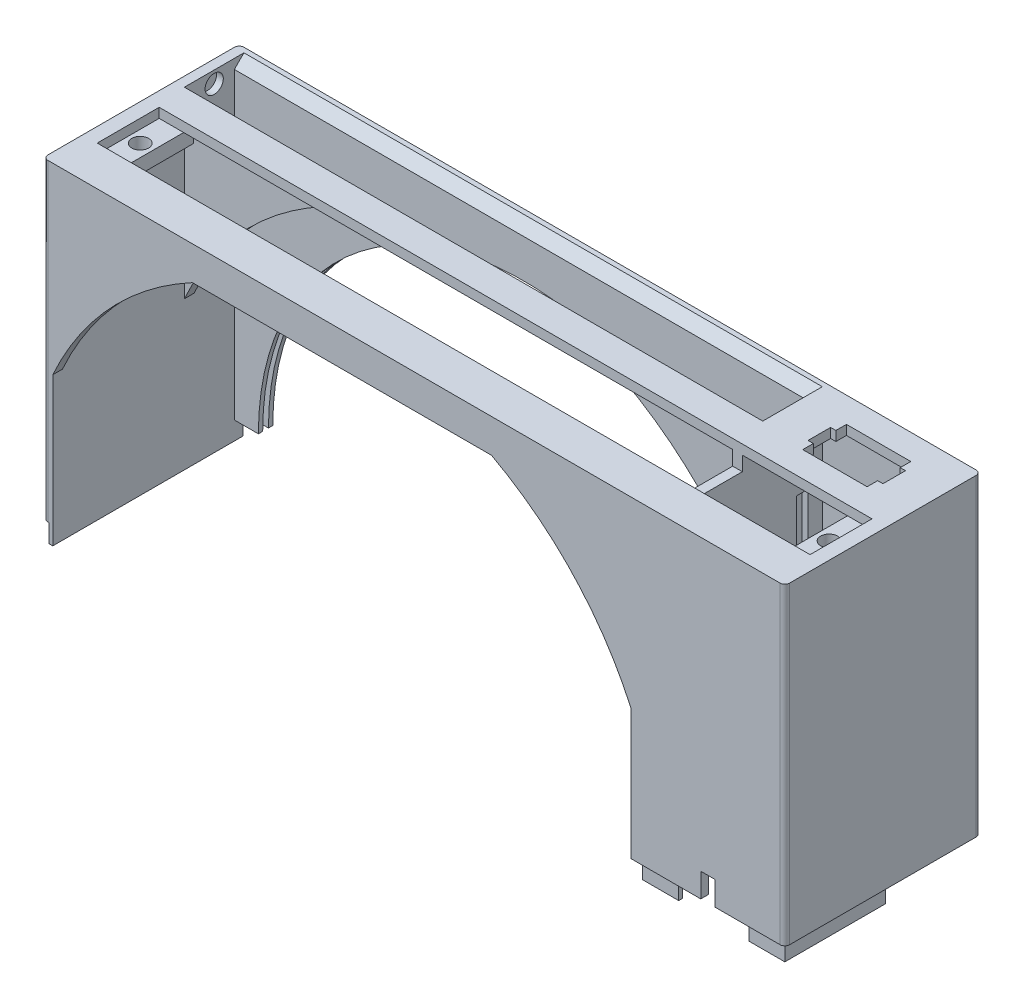
from build123d import *

# Parameters (mm, degrees)
ESQUISSE1_W              = 154.4
ESQUISSE1_H              = 40.8
BOSS_EXTRU_1_DEPTH       = 2
ESQUISSE2_W              = 154.4
ESQUISSE2_H              = 40.8
ESQUISSE2_W_2            = 120.4
ESQUISSE2_H_2            = 25.4
ESQUISSE2_H_3            = 8.4
ESQUISSE2_W_3            = 28
ESQUISSE2_H_4            = 35.8
BOSS_EXTRU_2_DEPTH       = 63.2
ENL_V_MAT_EXTRU_1_DEPTH  = 29.4
ESQUISSE8_W              = 9
ESQUISSE8_H              = 8.8
ENL_V_MAT_EXTRU_3_DEPTH  = 0.4
ESQUISSE9_W              = 3
ESQUISSE9_H              = 5
ENL_V_MAT_EXTRU_4_DEPTH  = 2.6
ESQUISSE10_W             = 1.2
ESQUISSE10_H             = 2.4
ENL_V_MAT_EXTRU_5_DEPTH  = 50.2
ESQUISSE12_W             = 0.8
ESQUISSE12_H             = 39.6
BOSS_EXTRU_3_DEPTH       = 3.8
ENL_V_MAT_EXTRU_6_REACH  = 71
ESQUISSE14_W             = 120.4
ESQUISSE14_H             = 8.4
ESQUISSE16_W             = 148.4
ESQUISSE16_H             = 12.9
ENL_V_MAT_EXTRU_8_DEPTH  = 2
ESQUISSE17_W             = 6.1
ESQUISSE17_H             = 16.9
ESQUISSE17_R             = 1.75
BOSS_EXTRU_5_DEPTH       = 3
ESQUISSE19_W             = 138.2
ESQUISSE19_H             = 12.9
ENL_V_MAT_EXTRU_10_DEPTH = 3
ESQUISSE20_R             = 1.9
ENL_V_MAT_EXTRU_11_DEPTH = 1.4
ESQUISSE21_R             = 1.9
ENL_V_MAT_EXTRU_12_DEPTH = 1.4
ENL_V_MAT_EXTRU_13_REACH = 42.8
ESQUISSE22_R             = 55.2
ENL_V_START              = -0.9
ESQUISSE23_R             = 58.2
ENL_V_MAT_EXTRU_14_DEPTH = 1.2
ENL_V_MAT_EXTRU_16_REACH = 71
ESQUISSE24_W             = 1.1
ESQUISSE24_H             = 4.7
ESQUISSE27_W             = 26
ESQUISSE27_H             = 3
ENL_V_MAT_EXTRU_17_DEPTH = 1.2
CONG_1_R                 = 1
CHANFREIN1_SIZE          = 2


with BuildPart() as part:
    # Esquisse1 → Boss.-Extru.1 (new body)
    with BuildSketch(Plane(origin=(0, 0, 0), x_dir=(1, 0, 0), z_dir=(0, 1, 0))):
        with Locations((77.2, 20.4)):
            Rectangle(ESQUISSE1_W, ESQUISSE1_H)
    extrude(amount=-BOSS_EXTRU_1_DEPTH)

    # Esquisse2 → Boss.-Extru.2 (add)
    with BuildSketch(Plane.XZ.offset(2)):
        with Locations((77.2, -20.4)):
            Rectangle(ESQUISSE2_W, ESQUISSE2_H)
        with Locations((62.2, -14.7)):
            Rectangle(ESQUISSE2_W_2, ESQUISSE2_H_2, mode=Mode.SUBTRACT)
        with Locations((62.2, -33.6)):
            Rectangle(ESQUISSE2_W_2, ESQUISSE2_H_3, mode=Mode.SUBTRACT)
        with Locations((138.4, -19.9)):
            Rectangle(ESQUISSE2_W_3, ESQUISSE2_H_4, mode=Mode.SUBTRACT)
    extrude(amount=BOSS_EXTRU_2_DEPTH)

    # Esquisse3 → Enl_v. mat.-Extru.1 (cut)
    with BuildSketch(Plane.XY):
        with BuildLine():
            Line((93.324909638, -7), (31.075090362, -7))
            ThreePointArc((31.075090362, -7), (13.955142399, -20.16186377), (2, -38.145240714))
            Line((2, -38.145240714), (2, -65.2))
            Line((2, -65.2), (122.4, -65.2))
            Line((122.4, -65.2), (122.4, -38.145240714))
            ThreePointArc((122.4, -38.145240714), (110.444857601, -20.16186377), (93.324909638, -7))
        make_face()
    extrude(amount=-ENL_V_MAT_EXTRU_1_DEPTH, mode=Mode.SUBTRACT)

    # Esquisse8 → Enl_v. mat.-Extru.3 (cut)
    with BuildSketch(Plane(origin=(0, 0, -2), x_dir=(-1, 0, 0), z_dir=(0, 0, -1))):
        with Locations((-138.4, -60.8)):
            Rectangle(ESQUISSE8_W, ESQUISSE8_H)
    extrude(amount=-ENL_V_MAT_EXTRU_3_DEPTH, mode=Mode.SUBTRACT)

    # Esquisse9 → Enl_v. mat.-Extru.4 (cut, through all)
    with BuildSketch(Plane(origin=(0, 0, -1.6), x_dir=(-1, 0, 0), z_dir=(0, 0, -1))):
        with Locations((-138.4, -62.7)):
            Rectangle(ESQUISSE9_W, ESQUISSE9_H)
    extrude(amount=-ENL_V_MAT_EXTRU_4_DEPTH, mode=Mode.SUBTRACT)

    # Esquisse10 → Enl_v. mat.-Extru.5 (cut)
    with BuildSketch(Plane.XZ.offset(65.2)):
        with Locations((153, -33.6)):
            Rectangle(ESQUISSE10_W, ESQUISSE10_H)
        with Locations((123.8, -33.6)):
            Rectangle(ESQUISSE10_W, ESQUISSE10_H)
    extrude(amount=-ENL_V_MAT_EXTRU_5_DEPTH, mode=Mode.SUBTRACT)

    # Esquisse12 → Boss.-Extru.3 (add)
    with BuildSketch(Plane.XZ.offset(65.2)):
        with Locations((1.6, -19.8)):
            Rectangle(ESQUISSE12_W, ESQUISSE12_H)
        Polygon((152.4, -2), (152.4, -22.2), (153.2, -22.2), (153.2, -1.2), (145.7, -1.2), (145.7, -2), align=None)
        Polygon((131.1, -2), (131.1, -1.2), (123.6, -1.2), (123.6, -22.2), (124.4, -22.2), (124.4, -2), align=None)
    extrude(amount=BOSS_EXTRU_3_DEPTH)

    # Esquisse14 → Enl_v. mat.-Extru.6 (cut, up to next)
    with BuildSketch(Plane(origin=(0, 0, 0), x_dir=(1, 0, 0), z_dir=(0, 1, 0)), mode=Mode.PRIVATE) as enl_v_mat_extru_6_sk1:
        with Locations((62.2, 33.6)):
            Rectangle(ESQUISSE14_W, ESQUISSE14_H)
    enl_v_mat_extru_6_tool1 = extrude(enl_v_mat_extru_6_sk1.sketch, amount=-ENL_V_MAT_EXTRU_6_REACH, mode=Mode.PRIVATE) & part.part
    add(enl_v_mat_extru_6_tool1.solids().sort_by_distance((62.2, 0, -33.6))[0], mode=Mode.SUBTRACT)

    # Esquisse16 → Enl_v. mat.-Extru.8 (cut)
    with BuildSketch(Plane(origin=(0, 0, 0), x_dir=(1, 0, 0), z_dir=(0, 1, 0))):
        with Locations((77.2, 14.7)):
            Rectangle(ESQUISSE16_W, ESQUISSE16_H)
    extrude(amount=-ENL_V_MAT_EXTRU_8_DEPTH, mode=Mode.SUBTRACT)

    # Esquisse17 → Boss.-Extru.5 (add)
    with BuildSketch(Plane.XZ.offset(2)):
        with Locations((5.05, -14.7)):
            Rectangle(ESQUISSE17_W, ESQUISSE17_H)
        with Locations((5.5, -14.7)):
            Circle(ESQUISSE17_R, mode=Mode.SUBTRACT)
        with Locations((149.35, -14.7)):
            Rectangle(ESQUISSE17_W, ESQUISSE17_H)
        with Locations((148.9, -14.7)):
            Circle(ESQUISSE17_R, mode=Mode.SUBTRACT)
    extrude(amount=BOSS_EXTRU_5_DEPTH)

    # Esquisse19 → Enl_v. mat.-Extru.10 (cut)
    with BuildSketch(Plane(origin=(0, -2, 0), x_dir=(1, 0, 0), z_dir=(0, 1, 0))):
        with Locations((77.2, 14.7)):
            Rectangle(ESQUISSE19_W, ESQUISSE19_H)
    extrude(amount=-ENL_V_MAT_EXTRU_10_DEPTH, mode=Mode.SUBTRACT)

    # Esquisse20 → Enl_v. mat.-Extru.11 (cut)
    with BuildSketch(Plane.ZY.offset(-122.4)):
        with Locations((-33.6, -2.5)):
            Circle(ESQUISSE20_R)
    extrude(amount=-ENL_V_MAT_EXTRU_11_DEPTH, mode=Mode.SUBTRACT)

    # Esquisse21 → Enl_v. mat.-Extru.12 (cut)
    with BuildSketch(Plane(origin=(2, 0, 0), x_dir=(0, 0, -1), z_dir=(1, 0, 0))):
        with Locations((33.6, -2.5)):
            Circle(ESQUISSE21_R)
    extrude(amount=-ENL_V_MAT_EXTRU_12_DEPTH, mode=Mode.SUBTRACT)

    # Esquisse22 → Enl_v. mat.-Extru.13 (cut, up to next)
    with BuildSketch(Plane(origin=(0, 0, -40.8), x_dir=(-1, 0, 0), z_dir=(0, 0, -1)), mode=Mode.PRIVATE) as enl_v_mat_extru_13_sk1:
        with Locations((-62.2, -65.2)):
            Circle(ESQUISSE22_R)
    enl_v_mat_extru_13_tool1 = extrude(enl_v_mat_extru_13_sk1.sketch, amount=-ENL_V_MAT_EXTRU_13_REACH, mode=Mode.PRIVATE) & part.part
    add(enl_v_mat_extru_13_tool1.solids().sort_by_distance((62.2, -65.2, -40.8))[0], mode=Mode.SUBTRACT)

    # Esquisse23 → Enl_v. mat.-Extru.14 (cut)
    with BuildSketch(Plane(origin=(0, 0, -40.8), x_dir=(-1, 0, 0), z_dir=(0, 0, -1)).offset(ENL_V_START)):
        with Locations((-62.2, -65.2)):
            Circle(ESQUISSE23_R)
    extrude(amount=-ENL_V_MAT_EXTRU_14_DEPTH, mode=Mode.SUBTRACT)

    # Esquisse24 → Enl_v. mat.-Extru.16 (cut, up to next)
    with BuildSketch(Plane(origin=(0, 0, 0), x_dir=(1, 0, 0), z_dir=(0, 1, 0)), mode=Mode.PRIVATE) as enl_v_mat_extru_16_sk1:
        Polygon((131.7, 35.525), (145.1, 35.525), (145.1, 26.425), (131.7, 26.425), (131.7, 28.625), (130.6, 28.625), (130.6, 33.325), (131.7, 33.325), align=None)
    enl_v_mat_extru_16_tool1 = extrude(enl_v_mat_extru_16_sk1.sketch, amount=-ENL_V_MAT_EXTRU_16_REACH, mode=Mode.PRIVATE) & part.part
    add(enl_v_mat_extru_16_tool1.solids().sort_by_distance((138.105118, 0, -30.975))[0], mode=Mode.SUBTRACT)
    # Esquisse24 → Enl_v. mat.-Extru.16 (cut, up to next)
    with BuildSketch(Plane(origin=(0, 0, 0), x_dir=(1, 0, 0), z_dir=(0, 1, 0)), mode=Mode.PRIVATE) as enl_v_mat_extru_16_sk2:
        with Locations((145.65, 30.975)):
            Rectangle(ESQUISSE24_W, ESQUISSE24_H)
    enl_v_mat_extru_16_tool2 = extrude(enl_v_mat_extru_16_sk2.sketch, amount=-ENL_V_MAT_EXTRU_16_REACH, mode=Mode.PRIVATE) & part.part
    add(enl_v_mat_extru_16_tool2.solids().sort_by_distance((145.65, 0, -30.975))[0], mode=Mode.SUBTRACT)

    # Esquisse27 → Enl_v. mat.-Extru.17 (cut)
    with BuildSketch(Plane.XY.offset(-37.8).offset(ENL_V_START)):
        with Locations((138.4, -63.7)):
            Rectangle(ESQUISSE27_W, ESQUISSE27_H)
    extrude(amount=-ENL_V_MAT_EXTRU_17_DEPTH, mode=Mode.SUBTRACT)

    # Cong_1
    cong_1_edges = [part.edges().sort_by_distance(p)[0] for p in [
        (0, -32.6, -40.8),
        (154.4, -32.6, -40.8),
        (154.4, -32.6, 0),
        (0, -32.6, 0),
    ]]
    fillet(cong_1_edges, radius=CONG_1_R)

    # Chanfrein1
    chanfrein1_edges = [part.edges().sort_by_distance(p)[0] for p in [
        (62.2, 0, -29.4),
        (62.2, 0, -37.8),
    ]]
    chamfer(chanfrein1_edges, length=CHANFREIN1_SIZE)


solid = part.part
